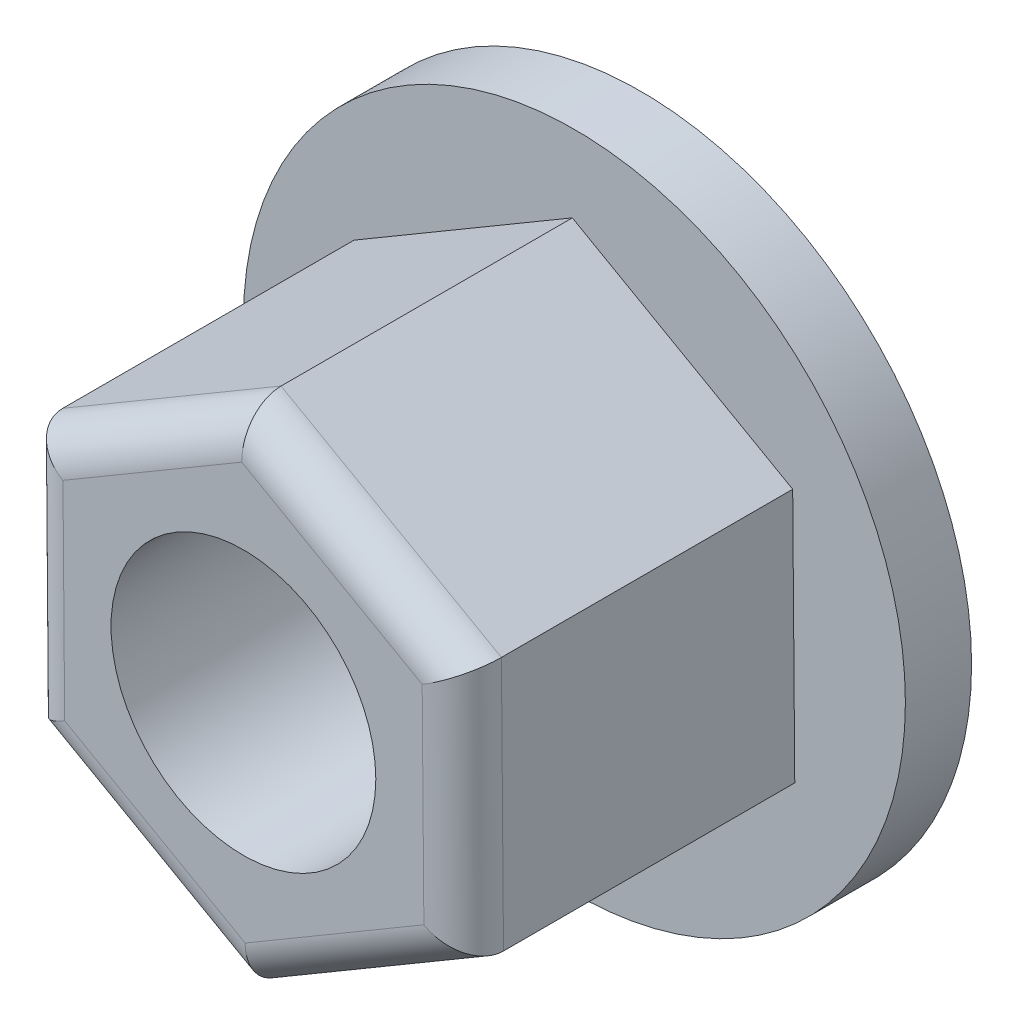
from build123d import *

# Parameters (mm, degrees)
SKETCH2_R           = 25
BOSS_EXTRUDE1_DEPTH = 5
BOSS_EXTRUDE2_DEPTH = 25
FILLET6_R           = 3
SKETCH5_R           = 10
CUT_EXTRUDE1_DEPTH  = 31


with BuildPart() as part:
    # Sketch2 → Boss-Extrude1 (new body)
    with BuildSketch(Plane.XY):
        Circle(SKETCH2_R)
    extrude(amount=BOSS_EXTRUDE1_DEPTH)

    # Sketch3 → Boss-Extrude2 (add)
    with BuildSketch(Plane.XY.offset(5)):
        Polygon((16.644393052, -9.427942918), (16.487034598, 9.700495755), (-0.157358454, 19.128438672), (-16.644393052, 9.427942918), (-16.487034598, -9.700495755), (0.157358454, -19.128438672), align=None)
    extrude(amount=BOSS_EXTRUDE2_DEPTH)

    # Fillet6
    fillet6_edges = [part.edges().sort_by_distance(p)[0] for p in [
        (8.400875753, -14.278190795, 30),
        (16.565713825, 0.136276419, 30),
        (8.164838072, 14.414467214, 30),
        (-8.400875753, 14.278190795, 30),
        (-16.565713825, -0.136276419, 30),
        (-8.164838072, -14.414467214, 30),
    ]]
    fillet(fillet6_edges, radius=FILLET6_R)

    # Sketch5 → Cut-Extrude1 (cut, through all)
    with BuildSketch(Plane.XY.offset(30)):
        Circle(SKETCH5_R)
    extrude(amount=-CUT_EXTRUDE1_DEPTH, mode=Mode.SUBTRACT)


solid = part.part
